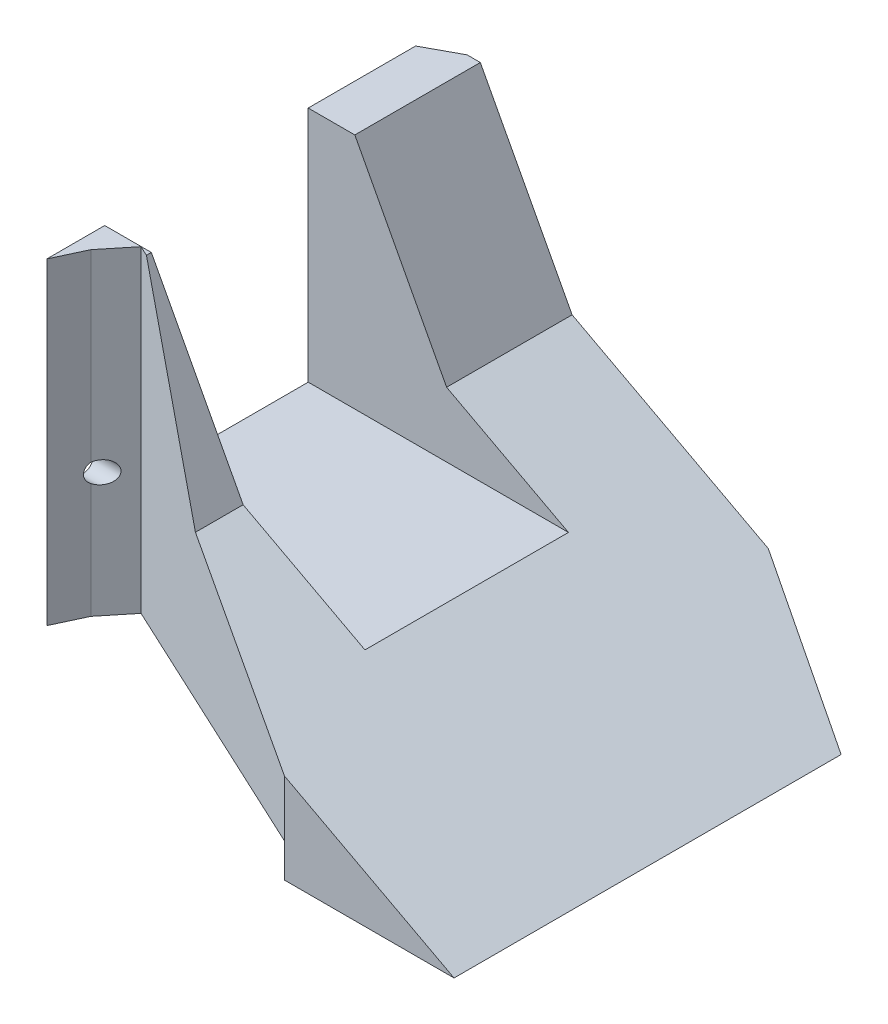
from build123d import *

# Parameters (mm, degrees)
CROQUIS1_W              = 67
CROQUIS1_H              = 51.82
SALIENTE_EXTRUIR1_DEPTH = 70
CORTAR_EXTRUIR1_REACH   = 69
CROQUIS4_W              = 60
CROQUIS4_H              = 30
CORTAR_EXTRUIR2_DEPTH   = 35
CORTAR_EXTRUIR3_REACH   = 69
CROQUIS5_W              = 45
CROQUIS5_H              = 5
CORTAR_EXTRUIR4_REACH   = 53.82
CORTAR_EXTRUIR5_REACH   = 53.82
CROQUIS9_R              = 1.6
CROQUIS9_R_2            = 1.522094027
CORTAR_EXTRUIR6_DEPTH   = 6
CROQUIS11_R             = 1.75
CORTAR_EXTRUIR7_DEPTH   = 6
CORTAR_EXTRUIR8_REACH   = 34.863


with BuildPart() as part:
    # Croquis1 → Saliente-Extruir1 (new body)
    with BuildSketch(Plane(origin=(0, 0, 0), x_dir=(0, 0, -1), z_dir=(1, 0, 0))):
        with Locations((33.5, 25.91)):
            Rectangle(CROQUIS1_W, CROQUIS1_H)
    extrude(amount=SALIENTE_EXTRUIR1_DEPTH)

    # Croquis3 → Cortar-Extruir1 (cut, up to next)
    with BuildSketch(Plane.XY, mode=Mode.PRIVATE) as cortar_extruir1_sk1:
        Polygon((70, 0), (20.404370982, 26.370463718), (6.872612509, 51.82), (70, 51.82), align=None)
    cortar_extruir1_tool1 = extrude(cortar_extruir1_sk1.sketch, amount=-CORTAR_EXTRUIR1_REACH, mode=Mode.PRIVATE) & part.part
    add(cortar_extruir1_tool1.solids().sort_by_distance((45.373987, 32.707801, 0))[0], mode=Mode.SUBTRACT)

    # Croquis4 → Cortar-Extruir2 (cut)
    with BuildSketch(Plane(origin=(0, 51.82, 0), x_dir=(1, 0, 0), z_dir=(0, 1, 0))):
        with Locations((30, 33.5)):
            Rectangle(CROQUIS4_W, CROQUIS4_H)
    extrude(amount=-CORTAR_EXTRUIR2_DEPTH, mode=Mode.SUBTRACT)

    # Croquis5 → Cortar-Extruir3 (cut, up to next)
    with BuildSketch(Plane.XY, mode=Mode.PRIVATE) as cortar_extruir3_sk1:
        with Locations((22.5, 2.5)):
            Rectangle(CROQUIS5_W, CROQUIS5_H)
    cortar_extruir3_tool1 = extrude(cortar_extruir3_sk1.sketch, amount=-CORTAR_EXTRUIR3_REACH, mode=Mode.PRIVATE) & part.part
    add(cortar_extruir3_tool1.solids().sort_by_distance((22.5, 2.5, 0))[0], mode=Mode.SUBTRACT)

    # Croquis6 → Cortar-Extruir4 (cut, up to next)
    with BuildSketch(Plane(origin=(0, 51.82, 0), x_dir=(1, 0, 0), z_dir=(0, 1, 0)), mode=Mode.PRIVATE) as cortar_extruir4_sk1:
        Polygon((4.922856145, 67), (0, 64.334655313), (0, 67), align=None)
    cortar_extruir4_tool1 = extrude(cortar_extruir4_sk1.sketch, amount=-CORTAR_EXTRUIR4_REACH, mode=Mode.PRIVATE) & part.part
    add(cortar_extruir4_tool1.solids().sort_by_distance((1.640952, 51.82, -66.111552))[0], mode=Mode.SUBTRACT)

    # Croquis8 → Cortar-Extruir5 (cut, up to next)
    with BuildSketch(Plane(origin=(0, 51.82, 0), x_dir=(1, 0, 0), z_dir=(0, 1, 0)), mode=Mode.PRIVATE) as cortar_extruir5_sk1:
        Polygon((45, 0), (5.376842989, 18.476581555), (2.059345913, 14.392541381), (0, 9.976259819), (0, -0.062203445), (6.872612509, 0), (20.404370982, 0), align=None)
    cortar_extruir5_tool1 = extrude(cortar_extruir5_sk1.sketch, amount=-CORTAR_EXTRUIR5_REACH, mode=Mode.PRIVATE) & part.part
    add(cortar_extruir5_tool1.solids().sort_by_distance((15.782883, 51.82, -6.412773))[0], mode=Mode.SUBTRACT)

    # Croquis9 → Cortar-Extruir6 (cut)
    with BuildSketch(Plane.ZY):
        with Locations((-15.25, 23.32)):
            Circle(CROQUIS9_R)
        with Locations((-52.25, 23.32)):
            Circle(CROQUIS9_R_2)
    extrude(amount=-CORTAR_EXTRUIR6_DEPTH, mode=Mode.SUBTRACT)

    # Croquis11 → Cortar-Extruir7 (cut)
    with BuildSketch(Plane.XZ.offset(-5)):
        with Locations((35, -58)):
            Circle(CROQUIS11_R)
        with Locations((10, -58)):
            Circle(CROQUIS11_R)
        with Locations((10, -38)):
            Circle(CROQUIS11_R)
        with Locations((35, -38)):
            Circle(CROQUIS11_R)
        with Locations((10, -19.30137405)):
            Circle(CROQUIS11_R)
        with Locations((35, -13)):
            Circle(CROQUIS11_R)
    extrude(amount=-CORTAR_EXTRUIR7_DEPTH, mode=Mode.SUBTRACT)

    # Croquis13 → Cortar-Extruir8 (cut, up to next)
    with BuildSketch(Plane(origin=(15.428248379, 29.016315039, 0), x_dir=(0.882947593, -0.469471563, 0), z_dir=(0.469471563, 0.882947593, 0)), mode=Mode.PRIVATE) as cortar_extruir8_sk1:
        Polygon((34.467850213, 68.66403013), (75.183132097, 51.381418335), (75.183132097, 68.66403013), align=None)
    cortar_extruir8_tool1 = extrude(cortar_extruir8_sk1.sketch, amount=-CORTAR_EXTRUIR8_REACH, mode=Mode.PRIVATE) & part.part
    add(cortar_extruir8_tool1.solids().sort_by_distance((69.827861, 0.091528, -62.90316))[0], mode=Mode.SUBTRACT)


solid = part.part
